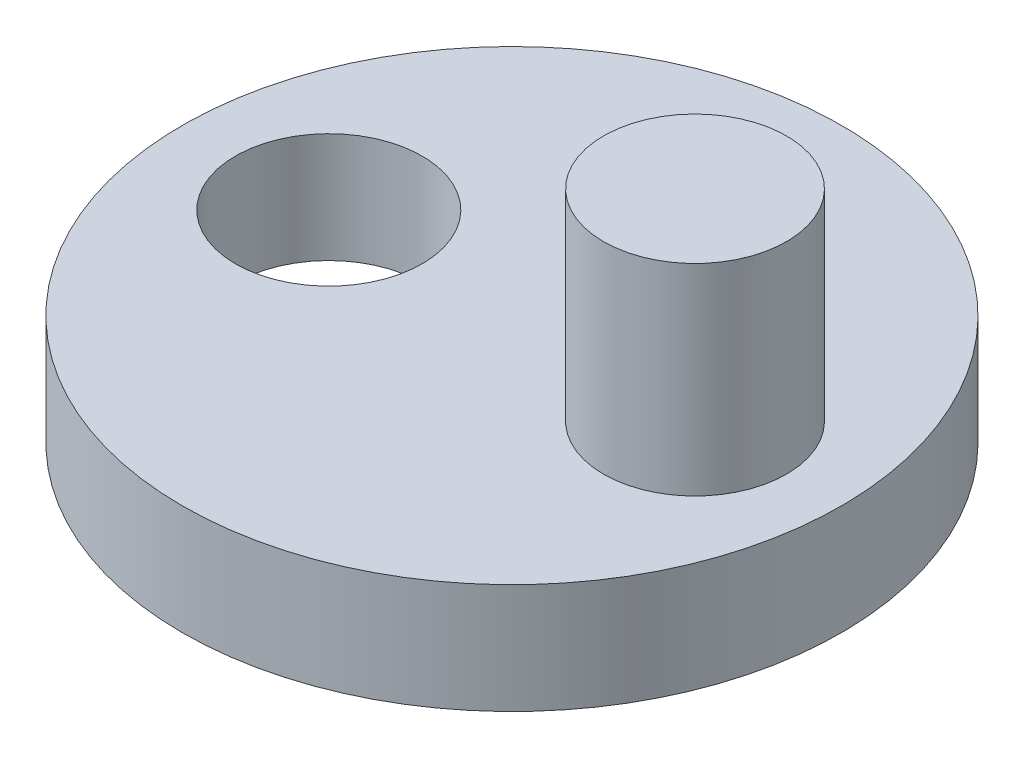
from build123d import *

# Parameters (mm, degrees)
SKETCH1_R           = 9
SKETCH1_R_2         = 2.55
BOSS_EXTRUDE1_DEPTH = 3
SKETCH2_R           = 2.5
BOSS_EXTRUDE2_DEPTH = 5.5


with BuildPart() as part:
    # Sketch1 → Boss-Extrude1 (new body)
    with BuildSketch(Plane(origin=(0, 0, 0), x_dir=(1, 0, 0), z_dir=(0, 1, 0))):
        Circle(SKETCH1_R)
        with Locations((-5, -0.000844513)):
            Circle(SKETCH1_R_2, mode=Mode.SUBTRACT)
    extrude(amount=BOSS_EXTRUDE1_DEPTH)

    # Sketch2 → Boss-Extrude2 (add)
    with BuildSketch(Plane(origin=(0, 3, 0), x_dir=(1, 0, 0), z_dir=(0, 1, 0))):
        with Locations((5, 0)):
            Circle(SKETCH2_R)
    extrude(amount=BOSS_EXTRUDE2_DEPTH)


solid = part.part
